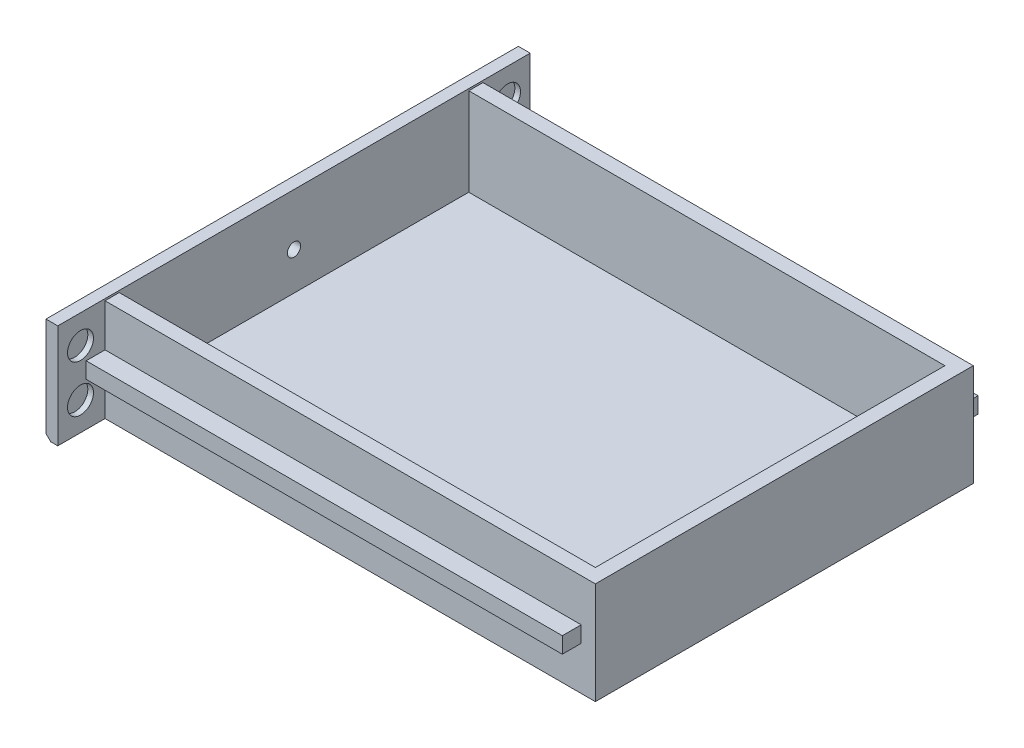
from build123d import *

# Parameters (mm, degrees)
CROQUIS1_W              = 100
CROQUIS1_H              = 22
SALIENTE_EXTRUIR1_DEPTH = 2.5
CROQUIS4_R              = 2.75
CORTAR_EXTRUIR2_DEPTH   = 1.2
SALIENTE_EXTRUIR2_DEPTH = 100.8
CROQUIS7_W              = 80
CROQUIS7_H              = 21.6
SALIENTE_EXTRUIR3_DEPTH = 3
CROQUIS8_R              = 1.4
CORTAR_EXTRUIR3_DEPTH   = 3
CHAFL_N1_SIZE           = 1


with BuildPart() as part:
    # Croquis1 → Saliente-Extruir1 (new body)
    with BuildSketch(Plane(origin=(0, 0, 0), x_dir=(0, 0, -1), z_dir=(1, 0, 0))):
        Rectangle(CROQUIS1_W, CROQUIS1_H)
    extrude(amount=SALIENTE_EXTRUIR1_DEPTH)

    # Croquis4 → Cortar-Extruir2 (cut)
    with BuildSketch(Plane(origin=(2.5, 0, 0), x_dir=(0, 0, -1), z_dir=(1, 0, 0))):
        with Locations((45.2, 5)):
            Circle(CROQUIS4_R)
        with Locations((45.2, -5)):
            Circle(CROQUIS4_R)
        with Locations((-45.2, 5)):
            Circle(CROQUIS4_R)
        with Locations((-45.2, -5)):
            Circle(CROQUIS4_R)
    extrude(amount=-CORTAR_EXTRUIR2_DEPTH, mode=Mode.SUBTRACT)

    # Croquis6 → Saliente-Extruir2 (add)
    with BuildSketch(Plane(origin=(2.5, 0, 0), x_dir=(0, 0, -1), z_dir=(1, 0, 0))):
        Polygon((-40, -11), (40, -11), (40, -1.8), (44, -1.8), (44, 1.6), (40, 1.6), (40, 10.6), (37, 10.6), (37, -8), (-37, -8), (-37, 10.6), (-40, 10.6), (-40, 1.6), (-44, 1.6), (-44, -1.8), (-40, -1.8), align=None)
    extrude(amount=SALIENTE_EXTRUIR2_DEPTH)

    # Croquis7 → Saliente-Extruir3 (add)
    with BuildSketch(Plane(origin=(103.3, 0, 0), x_dir=(0, 0, -1), z_dir=(1, 0, 0))):
        with Locations((0, -0.2)):
            Rectangle(CROQUIS7_W, CROQUIS7_H)
    extrude(amount=SALIENTE_EXTRUIR3_DEPTH)

    # Croquis8 → Cortar-Extruir3 (cut)
    with BuildSketch(Plane.ZY):
        Circle(CROQUIS8_R)
    extrude(amount=-CORTAR_EXTRUIR3_DEPTH, mode=Mode.SUBTRACT)

    # Chaflán1
    chafl_n1_edges = [part.edges().sort_by_distance(p)[0] for p in [
        (0, -11, 0),
    ]]
    chamfer(chafl_n1_edges, length=CHAFL_N1_SIZE)


solid = part.part
